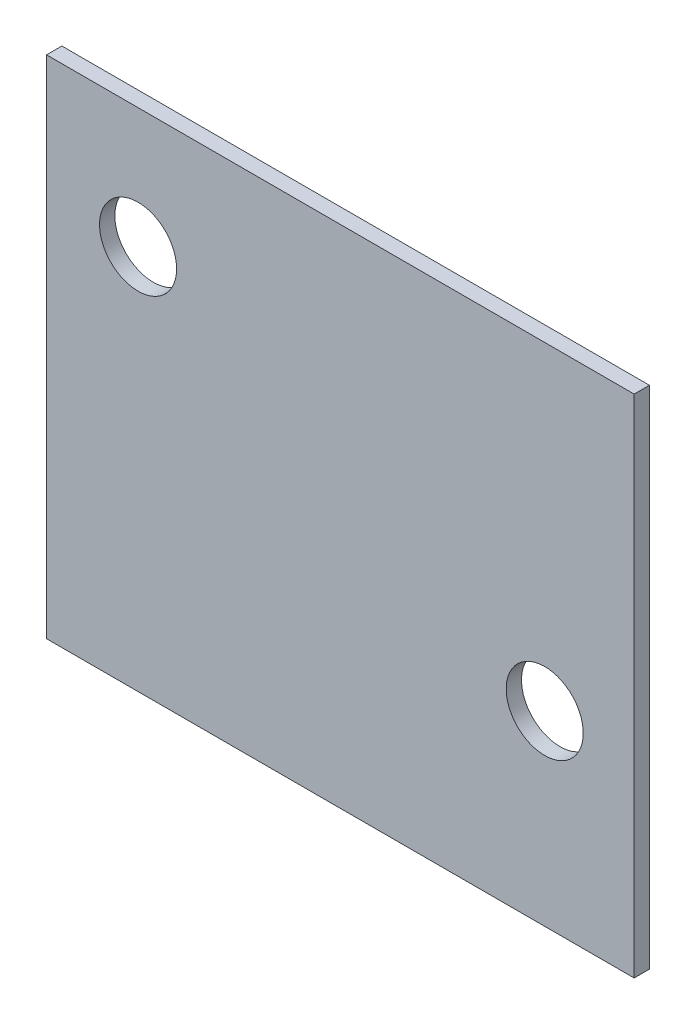
from build123d import *

# Parameters (mm, degrees)
SKETCH1_W           = 122
SKETCH1_H           = 105
SKETCH1_R           = 8
BOSS_EXTRUDE1_DEPTH = 3.175


with BuildPart() as part:
    # Sketch1 → Boss-Extrude1 (new body)
    with BuildSketch(Plane.XY):
        with Locations((42, -27.5)):
            Rectangle(SKETCH1_W, SKETCH1_H)
        with Locations((84.431124445, -41.275)):
            Circle(SKETCH1_R, mode=Mode.SUBTRACT)
        Circle(SKETCH1_R, mode=Mode.SUBTRACT)
    extrude(amount=-BOSS_EXTRUDE1_DEPTH)


solid = part.part
